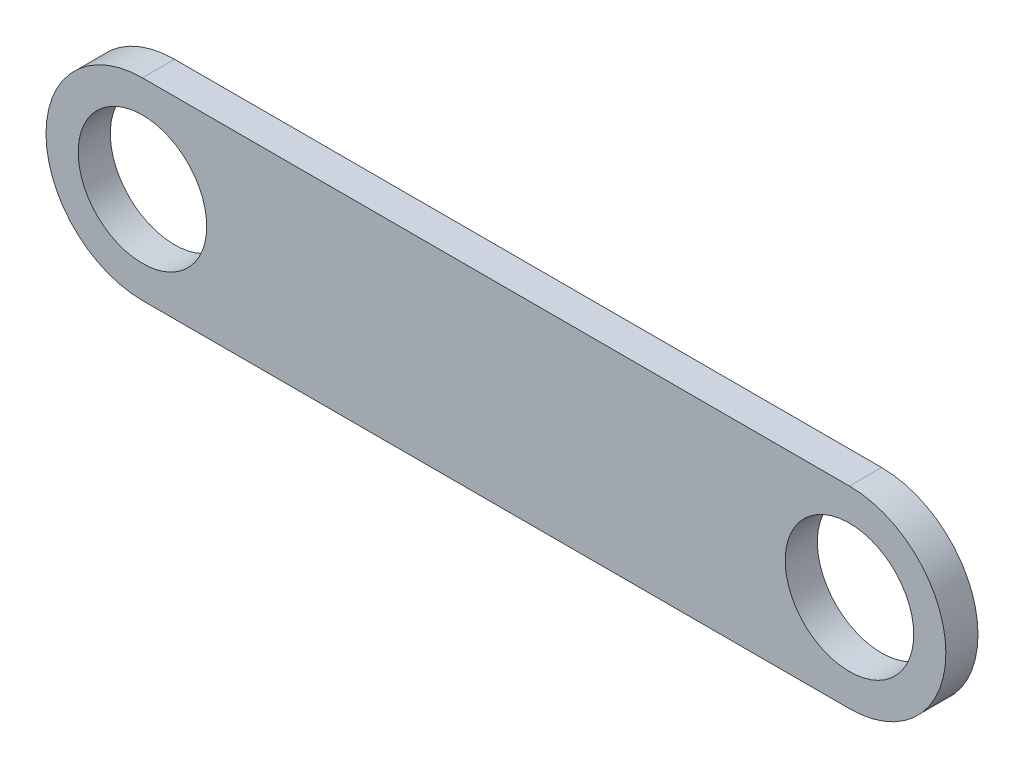
from build123d import *

# Parameters (mm, degrees)
CROQUIS1_R              = 10
SALIENTE_EXTRUIR1_DEPTH = 5


with BuildPart() as part:
    # Croquis1 → Saliente-Extruir1 (new body)
    with BuildSketch(Plane.XY):
        with BuildLine():
            Line((-53.125, 17.1875), (56.875, 17.1875))
            ThreePointArc((56.875, 17.1875), (71.875, 2.1875), (56.875, -12.8125))
            Line((56.875, -12.8125), (-53.125, -12.8125))
            ThreePointArc((-53.125, -12.8125), (-68.125, 2.1875), (-53.125, 17.1875))
        make_face()
        with Locations((-53.125, 2.1875)):
            Circle(CROQUIS1_R, mode=Mode.SUBTRACT)
        with Locations((56.875, 2.1875)):
            Circle(CROQUIS1_R, mode=Mode.SUBTRACT)
    extrude(amount=SALIENTE_EXTRUIR1_DEPTH)


solid = part.part
